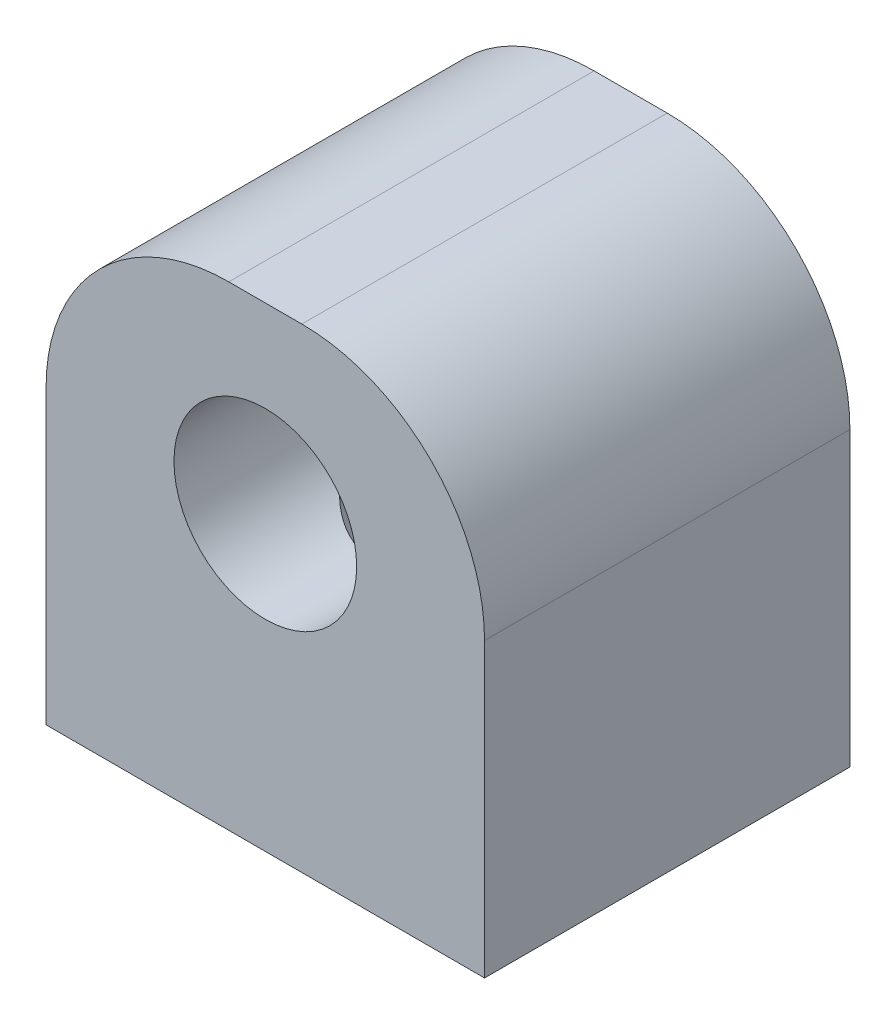
from build123d import *

# Parameters (mm, degrees)
ESQUISSE1_W        = 12
ESQUISSE1_H        = 13
BOSS_EXTRU_1_DEPTH = 10
ESQUISSE3_W        = 2.5
ESQUISSE3_H        = 10
ESQUISSE4_W        = 2.1
ESQUISSE4_H        = 8
CONG_1_R           = 5


with BuildPart() as part:
    # Esquisse1 → Boss.-Extru.1 (new body)
    with BuildSketch(Plane(origin=(0, 0, 0), x_dir=(-1, 0, 0), z_dir=(0, 0, -1))):
        with Locations((0, -1.5)):
            Rectangle(ESQUISSE1_W, ESQUISSE1_H)
    extrude(amount=-BOSS_EXTRU_1_DEPTH)

    # Esquisse3 → Enlèvement de matière-Révolution1 (revolve, cut)
    with BuildSketch(Plane(origin=(0, 0, 0), x_dir=(1, 0, 0), z_dir=(0, 1, 0))):
        with Locations((1.25, -5)):
            Rectangle(ESQUISSE3_W, ESQUISSE3_H)
    revolve(axis=Axis((0, 0, 0), (0, 0, 1)), mode=Mode.SUBTRACT)

    # Esquisse4 → Diamètre du perçage Ø5.6 (5.6)1 (revolve, cut)
    with BuildSketch(Plane(origin=(0, 0, 5), x_dir=(0, 0, 1), z_dir=(1, 0, 0))):
        with Locations((1.05, 4)):
            Rectangle(ESQUISSE4_W, ESQUISSE4_H)
    revolve(axis=Axis((0, 6.35, 5), (0, -1, 0)), mode=Mode.SUBTRACT)

    # Congé1
    cong_1_edges = [part.edges().sort_by_distance(p)[0] for p in [
        (6, 5, 5),
        (-6, 5, 5),
    ]]
    fillet(cong_1_edges, radius=CONG_1_R)


solid = part.part
